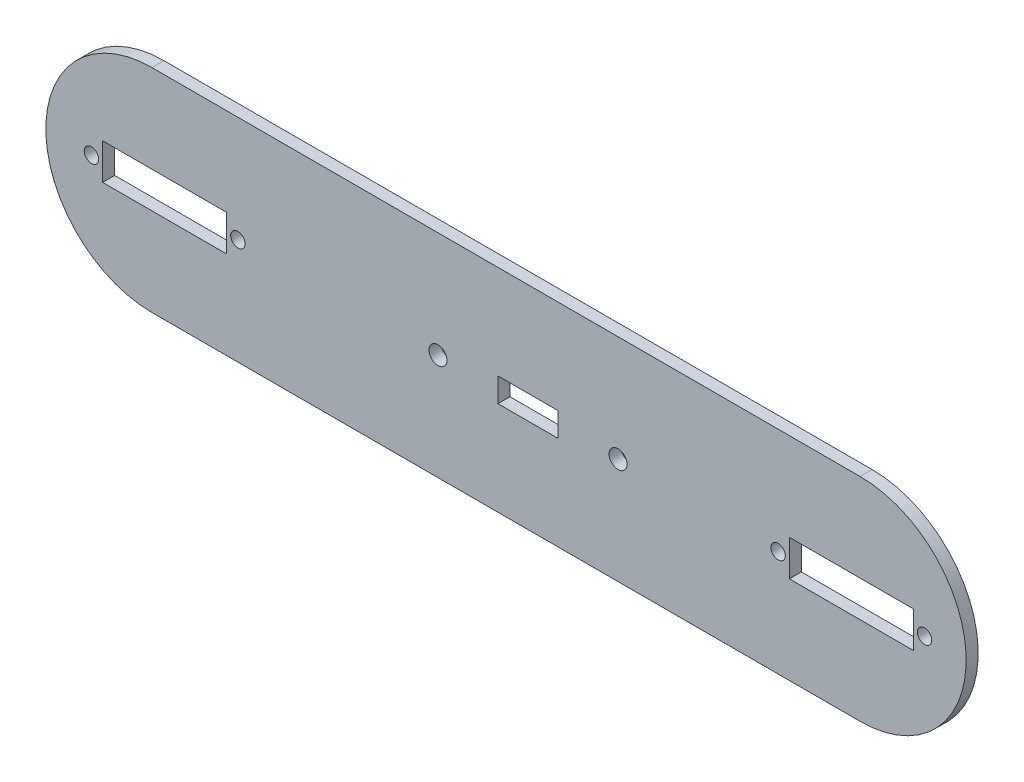
from build123d import *

# Parameters (mm, degrees)
ESBO_O1_R                = 2.25
ESBO_O1_R_2              = 1.8
ESBO_O1_W                = 15
ESBO_O1_H                = 6
ESBO_O1_W_2              = 31
ESBO_O1_H_2              = 9
RESSALTO_EXTRUS_O1_DEPTH = 3


with BuildPart() as part:
    # Esboço1 → Ressalto-extrusão1 (new body)
    with BuildSketch(Plane.XY):
        with BuildLine():
            Line((-94, 26.5), (83, 26.5))
            ThreePointArc((83, 26.5), (109.5, 0), (83, -26.5))
            Line((83, -26.5), (-94, -26.5))
            ThreePointArc((-94, -26.5), (-120.5, 0), (-94, 26.5))
        make_face()
        with Locations((-22.5, 0)):
            Circle(ESBO_O1_R, mode=Mode.SUBTRACT)
        with Locations((22.5, 0)):
            Circle(ESBO_O1_R, mode=Mode.SUBTRACT)
        with Locations((-109.1, 0)):
            Circle(ESBO_O1_R_2, mode=Mode.SUBTRACT)
        with Locations((-72.5, 0)):
            Circle(ESBO_O1_R_2, mode=Mode.SUBTRACT)
        with Locations((62.5, 0)):
            Circle(ESBO_O1_R_2, mode=Mode.SUBTRACT)
        with Locations((99.1, 0)):
            Circle(ESBO_O1_R_2, mode=Mode.SUBTRACT)
        Rectangle(ESBO_O1_W, ESBO_O1_H, mode=Mode.SUBTRACT)
        with Locations((-90.8, 0)):
            Rectangle(ESBO_O1_W_2, ESBO_O1_H_2, mode=Mode.SUBTRACT)
        with Locations((80.8, 0)):
            Rectangle(ESBO_O1_W_2, ESBO_O1_H_2, mode=Mode.SUBTRACT)
    extrude(amount=RESSALTO_EXTRUS_O1_DEPTH)


solid = part.part
